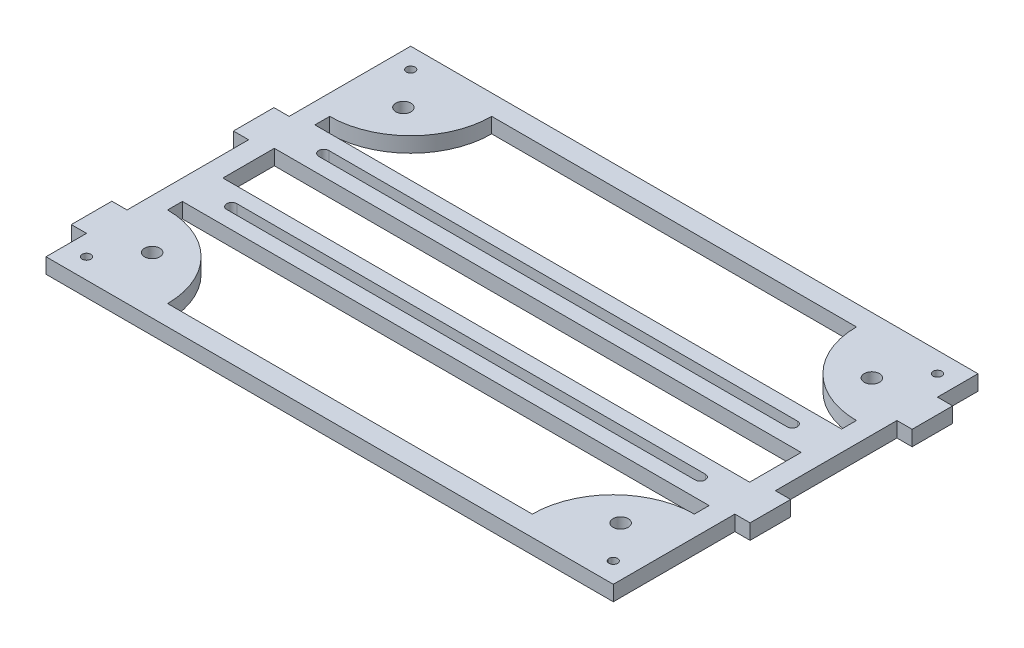
from build123d import *

# Parameters (mm, degrees)
SKETCH1_W             = 177.8
SKETCH1_H             = 114.3
SKETCH1_W_2           = 165.1
SKETCH1_H_2           = 16.134929366
BOSS_EXTRUDE1_DEPTH   = 4.7625
CUT_EXTRUDE1_DEPTH    = 5.7625
SKETCH4_R             = 2.38125
CUT_EXTRUDE2_DEPTH    = 5.7625
F_6_32_TAPPED_HOLE1_D = 2.7051
SKETCH7_W             = 12.7
SKETCH7_H             = 4.7625
BOSS_EXTRUDE2_DEPTH   = 4.7625
SKETCH8_W             = 12.7
SKETCH8_H             = 4.7625
BOSS_EXTRUDE3_DEPTH   = 4.7625


with BuildPart() as part:
    # Sketch1 → Boss-Extrude1 (new body)
    with BuildSketch(Plane(origin=(0, 0, 0), x_dir=(1, 0, 0), z_dir=(0, 1, 0))):
        Rectangle(SKETCH1_W, SKETCH1_H)
        with BuildLine():
            Line((-82.55, -25.4), (-82.55, -20.767464683))
            Line((-82.55, -20.767464683), (82.55, -20.767464683))
            Line((82.55, -20.767464683), (82.55, -25.4))
            ThreePointArc((82.55, -25.4), (64.589487758, -32.839487758), (57.15, -50.8))
            Line((57.15, -50.8), (-57.15, -50.8))
            ThreePointArc((-57.15, -50.8), (-64.589487758, -32.839487758), (-82.55, -25.4))
        make_face(mode=Mode.SUBTRACT)
        Rectangle(SKETCH1_W_2, SKETCH1_H_2, mode=Mode.SUBTRACT)
        with BuildLine():
            Line((82.55, 20.767464683), (-82.55, 20.767464683))
            Line((-82.55, 20.767464683), (-82.55, 25.4))
            ThreePointArc((-82.55, 25.4), (-64.589487758, 32.839487758), (-57.15, 50.8))
            Line((-57.15, 50.8), (57.15, 50.8))
            ThreePointArc((57.15, 50.8), (64.589487758, 32.839487758), (82.55, 25.4))
            Line((82.55, 25.4), (82.55, 20.767464683))
        make_face(mode=Mode.SUBTRACT)
    extrude(amount=BOSS_EXTRUDE1_DEPTH)

    # Sketch3 → Cut-Extrude1 (cut, through all)
    with BuildSketch(Plane(origin=(0, 4.7625, 0), x_dir=(1, 0, 0), z_dir=(0, 1, 0))):
        with BuildLine():
            Line((-73.406, 16.004964683), (73.406, 16.004964683))
            ThreePointArc((73.406, 16.004964683), (74.9935, 14.417464683), (73.406, 12.829964683))
            Line((73.406, 12.829964683), (-73.406, 12.829964683))
            ThreePointArc((-73.406, 12.829964683), (-74.9935, 14.417464683), (-73.406, 16.004964683))
        make_face()
        with BuildLine():
            Line((-73.406, -16.004964683), (73.406, -16.004964683))
            ThreePointArc((73.406, -16.004964683), (74.9935, -14.417464683), (73.406, -12.829964683))
            Line((73.406, -12.829964683), (-73.406, -12.829964683))
            ThreePointArc((-73.406, -12.829964683), (-74.9935, -14.417464683), (-73.406, -16.004964683))
        make_face()
    extrude(amount=-CUT_EXTRUDE1_DEPTH, mode=Mode.SUBTRACT)

    # Sketch4 → Cut-Extrude2 (cut, through all)
    with BuildSketch(Plane(origin=(0, 4.7625, 0), x_dir=(1, 0, 0), z_dir=(0, 1, 0))):
        with Locations((-73.406, 39.37)):
            Circle(SKETCH4_R)
        with Locations((-73.406, -39.37)):
            Circle(SKETCH4_R)
        with Locations((73.406, -39.37)):
            Circle(SKETCH4_R)
        with Locations((73.406, 39.37)):
            Circle(SKETCH4_R)
    extrude(amount=-CUT_EXTRUDE2_DEPTH, mode=Mode.SUBTRACT)

    # #6-32 Tapped Hole1 (through all)
    with Locations(Plane(origin=(0, 6.2865, 0), x_dir=(-1, 0, 0), z_dir=(0, 1, 0))):
        with Locations((82.55, -50.8), (82.55, 50.8), (-82.55, 50.8), (-82.55, -50.8)):
            Hole(F_6_32_TAPPED_HOLE1_D / 2)

    # Sketch7 → Boss-Extrude2 (add)
    with BuildSketch(Plane.ZY.offset(88.9)):
        with Locations((-12.7, 2.38125)):
            Rectangle(SKETCH7_W, SKETCH7_H)
        with Locations((38.1, 2.38125)):
            Rectangle(SKETCH7_W, SKETCH7_H)
    extrude(amount=BOSS_EXTRUDE2_DEPTH)

    # Sketch8 → Boss-Extrude3 (add)
    with BuildSketch(Plane(origin=(88.9, 0, 0), x_dir=(0, 0, -1), z_dir=(1, 0, 0))):
        with Locations((-12.7, 2.38125)):
            Rectangle(SKETCH8_W, SKETCH8_H)
        with Locations((38.1, 2.38125)):
            Rectangle(SKETCH8_W, SKETCH8_H)
    extrude(amount=BOSS_EXTRUDE3_DEPTH)


solid = part.part
